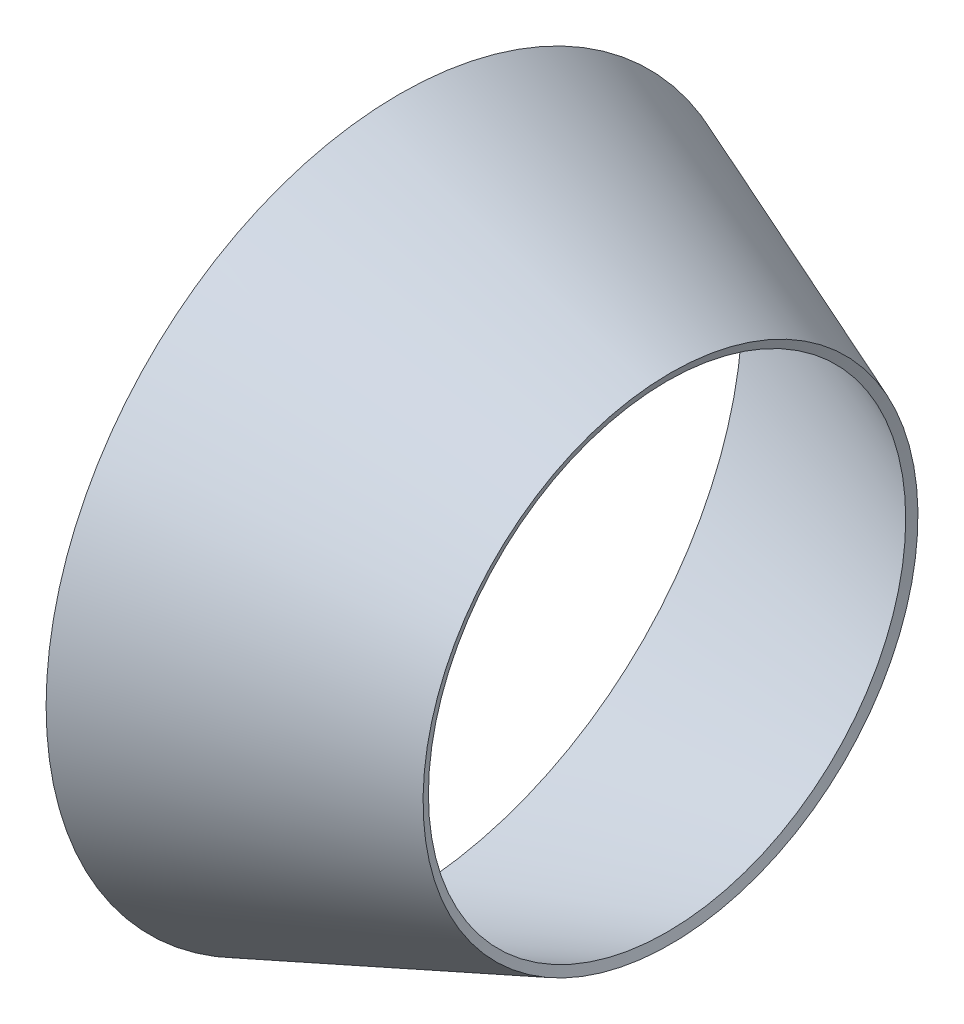
from build123d import *


with BuildPart() as part:
    # Sketch1 → Revolve1 (revolve)
    with BuildSketch(Plane.XY):
        Polygon((-42.091303455, -47.516051224), (-5.625954828, -33.281096789), (-6.087782578, -32.098043481), (-42.091303455, -46.152714518), align=None)
    revolve(axis=Axis((0, 0, 0), (-1, 0, 0)))


solid = part.part
